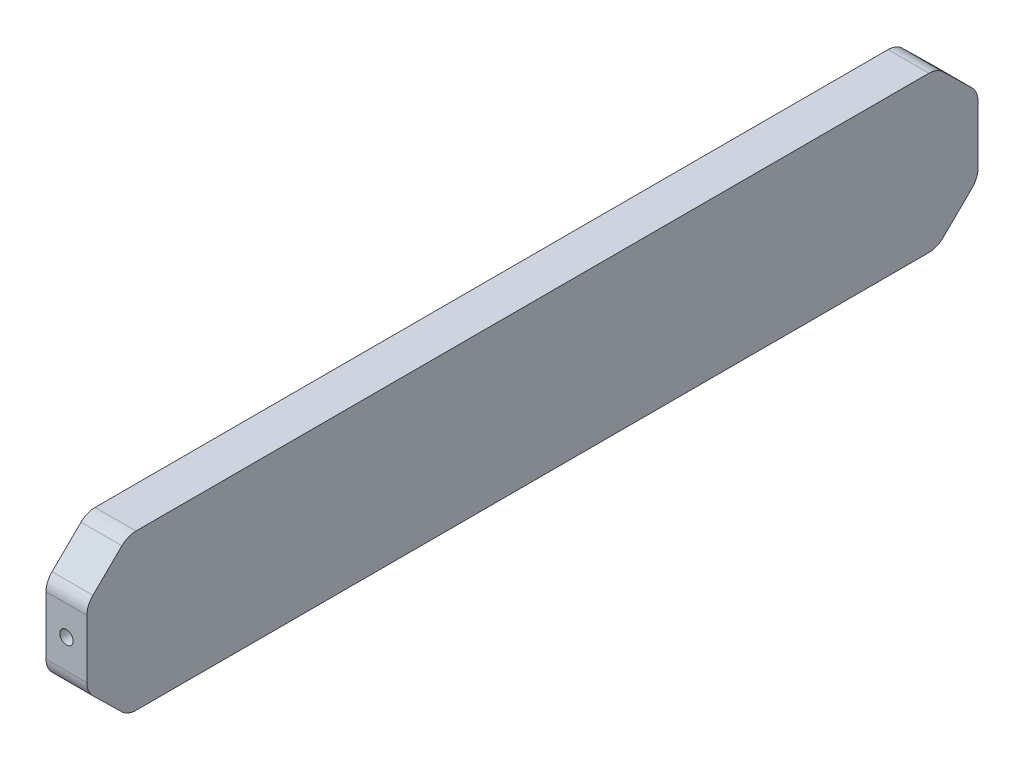
from build123d import *

# Parameters (mm, degrees)
SKETCH1_W                        = 10
SKETCH1_H                        = 218
BOSS_EXTRUDE1_DEPTH              = 38
CUT_EXTRUDE1_DEPTH               = 11
FILLET1_R                        = 4.92
F_30_0_1285_DIAMETER_HOLE1_D     = 3.2639
F_30_0_1285_DIAMETER_HOLE1_DEPTH = 9.99998
F_30_0_1285_DIAMETER_HOLE1_TIP   = 0.980574487
F_30_0_1285_DIAMETER_HOLE2_D     = 3.2639
F_30_0_1285_DIAMETER_HOLE2_DEPTH = 9.906
F_30_0_1285_DIAMETER_HOLE2_TIP   = 0.980574487


with BuildPart() as part:
    # Sketch1 → Boss-Extrude1 (new body)
    with BuildSketch(Plane(origin=(0, 0, 0), x_dir=(1, 0, 0), z_dir=(0, 1, 0))):
        with Locations((5, 109)):
            Rectangle(SKETCH1_W, SKETCH1_H)
    extrude(amount=BOSS_EXTRUDE1_DEPTH)

    # Sketch3 → Cut-Extrude1 (cut, through all)
    with BuildSketch(Plane(origin=(0, 0, 0), x_dir=(0, 0, -1), z_dir=(1, 0, 0))):
        Polygon((218, 38), (208, 38), (218, 28.202041029), align=None)
        Polygon((218, 9.797958971), (218, 0), (208, 0), align=None)
        Polygon((0, 0), (10, 0), (0, 9.797958971), align=None)
        Polygon((0, 28.202041029), (0, 38), (10, 38), align=None)
    extrude(amount=CUT_EXTRUDE1_DEPTH, mode=Mode.SUBTRACT)

    # Fillet1
    fillet1_edges = [part.edges().sort_by_distance(p)[0] for p in [
        (5, 28.202041029, 0),
        (5, 38, -10),
        (5, 9.797958971, 0),
        (5, 0, -10),
        (5, 9.797958971, -218),
        (5, 0, -208),
        (5, 28.202041029, -218),
        (5, 38, -208),
    ]]
    fillet(fillet1_edges, radius=FILLET1_R)

    # #30 (0.1285) Diameter Hole1
    with Locations(Plane.XY):
        with Locations((5, 19)):
            Hole(F_30_0_1285_DIAMETER_HOLE1_D / 2, depth=F_30_0_1285_DIAMETER_HOLE1_DEPTH)
            with Locations((0, 0, -(F_30_0_1285_DIAMETER_HOLE1_DEPTH + F_30_0_1285_DIAMETER_HOLE1_TIP / 2))):  # 118° drill point
                Cone(0, F_30_0_1285_DIAMETER_HOLE1_D / 2, F_30_0_1285_DIAMETER_HOLE1_TIP, mode=Mode.SUBTRACT)

    # #30 (0.1285) Diameter Hole2
    with Locations(Plane(origin=(0, 0, -218), x_dir=(-1, 0, 0), z_dir=(0, 0, -1))):
        with Locations((-5, 19)):
            Hole(F_30_0_1285_DIAMETER_HOLE2_D / 2, depth=F_30_0_1285_DIAMETER_HOLE2_DEPTH)
            with Locations((0, 0, -(F_30_0_1285_DIAMETER_HOLE2_DEPTH + F_30_0_1285_DIAMETER_HOLE2_TIP / 2))):  # 118° drill point
                Cone(0, F_30_0_1285_DIAMETER_HOLE2_D / 2, F_30_0_1285_DIAMETER_HOLE2_TIP, mode=Mode.SUBTRACT)


solid = part.part
